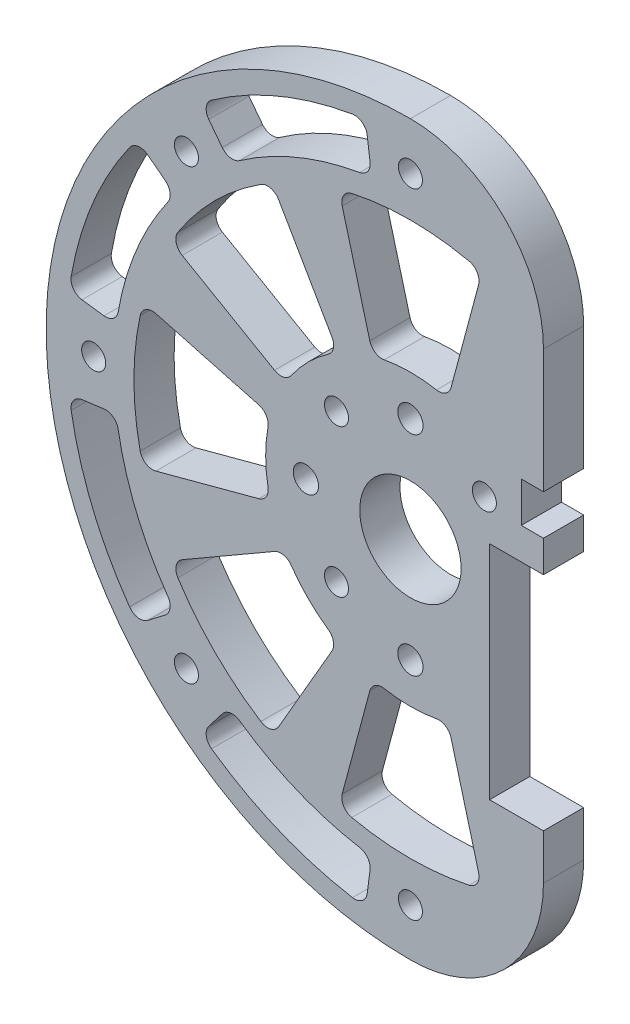
from build123d import *

# Parameters (mm, degrees)
SKETCH1_R                = 57.5
SKETCH1_R_2              = 1.89865
SKETCH1_R_3              = 1.9939
SKETCH1_R_4              = 8
BOSS_EXTRUDE1_DEPTH      = 6.35
CUT_EXTRUDE1_DEPTH       = 82.564836173
SKETCH3_W                = 6.35
SKETCH3_H                = 80
CUT_EXTRUDE3_DEPTH       = 82.564836173
CUT_EXTRUDE5_DEPTH       = 82.564836173
CUT_EXTRUDE7_DEPTH       = 82.564836173
FILLET1_R                = 2
CIRPATTERN1_COUNT        = 8
FILLET1_OF_CIRPATTERN1_R = 2
CUT_EXTRUDE8_DEPTH       = 82.564836173
FILLET2_R                = 2
CIRPATTERN2_COUNT        = 8
FILLET2_OF_CIRPATTERN2_R = 2


with BuildPart() as part:
    # Sketch1 → Boss-Extrude1 (new body)
    with BuildSketch(Plane.XY):
        Circle(SKETCH1_R)
        with Locations((45.315389352, 21.130913087)):
            Circle(SKETCH1_R_2, mode=Mode.SUBTRACT)
        with Locations((49.978847504, 1.454235937)):
            Circle(SKETCH1_R_3, mode=Mode.SUBTRACT)
        Circle(SKETCH1_R_4, mode=Mode.SUBTRACT)
        with Locations((46.467376211, -18.460307366)):
            Circle(SKETCH1_R_3, mode=Mode.SUBTRACT)
        with Locations((0, -16.5)):
            Circle(SKETCH1_R_3, mode=Mode.SUBTRACT)
        with Locations((0, -50)):
            Circle(SKETCH1_R_2, mode=Mode.SUBTRACT)
        with Locations((-16.5, 0)):
            Circle(SKETCH1_R_3, mode=Mode.SUBTRACT)
        with Locations((-11.66726189, -11.66726189)):
            Circle(SKETCH1_R_2, mode=Mode.SUBTRACT)
        with Locations((0, 16.5)):
            Circle(SKETCH1_R_3, mode=Mode.SUBTRACT)
        with Locations((-11.66726189, 11.66726189)):
            Circle(SKETCH1_R_2, mode=Mode.SUBTRACT)
        with Locations((11.66726189, 11.66726189)):
            Circle(SKETCH1_R_2, mode=Mode.SUBTRACT)
        with Locations((-35.355339059, -35.355339059)):
            Circle(SKETCH1_R_2, mode=Mode.SUBTRACT)
        with Locations((-50, 0)):
            Circle(SKETCH1_R_2, mode=Mode.SUBTRACT)
        with Locations((-35.355339059, 35.355339059)):
            Circle(SKETCH1_R_2, mode=Mode.SUBTRACT)
        with Locations((0, 50)):
            Circle(SKETCH1_R_2, mode=Mode.SUBTRACT)
        with Locations((35.355339059, -35.355339059)):
            Circle(SKETCH1_R_2, mode=Mode.SUBTRACT)
    extrude(amount=BOSS_EXTRUDE1_DEPTH)

    # Sketch2 → Cut-Extrude1 (cut, through all)
    with BuildSketch(Plane.XY):
        Polygon((12.5, -29.35), (41, -29.35), (41, 10.65), (44.5, 10.65), (44.5, 17), (41, 17), (41, 32), (21, 32), (21, 17), (17.5, 17), (17.5, 10.65), (21, 10.65), (21, 5.65), (12.5, 5.65), align=None)
    extrude(amount=CUT_EXTRUDE1_DEPTH, mode=Mode.SUBTRACT)

    # Sketch3 → Cut-Extrude3 (cut, through all)
    with BuildSketch(Plane(origin=(0, 0, 0), x_dir=(-1, 0, 0), z_dir=(0, 0, -1))):
        with Locations((-31, 32)):
            Rectangle(SKETCH3_W, SKETCH3_H)
    extrude(amount=-CUT_EXTRUDE3_DEPTH, mode=Mode.SUBTRACT)

    # Sketch4 → Cut-Extrude5 (cut, through all)
    with BuildSketch(Plane.XY):
        with BuildLine():
            Line((21, -36.500002949), (21, -5.372089924))
            Line((21, -5.372089924), (24.175, -5.411516926))
            Line((24.175, -5.411516926), (24.175, -57.5))
            Line((24.175, -57.5), (2.949e-06, -57.5))
            ThreePointArc((2.949e-06, -57.5), (14.849243269, -51.349243269), (21, -36.500002949))
        make_face()
        with BuildLine():
            Line((2.949e-06, 57.5), (24.175, 57.5))
            Line((24.175, 57.5), (24.175, 5.411516926))
            Line((24.175, 5.411516926), (21, 5.372089924))
            Line((21, 5.372089924), (21, 36.500002949))
            ThreePointArc((21, 36.500002949), (14.849243269, 51.349243269), (2.949e-06, 57.5))
        make_face()
    extrude(amount=CUT_EXTRUDE5_DEPTH, mode=Mode.SUBTRACT)


with BuildPart() as cut_extrude5_kept_piece:
    # of the separate pieces the step leaves, the one the design keeps (cut_extrude5_pieces_kept)
    add(part.part.solids().sort_by_distance((2.949e-06, 57.5, 0))[0])

    # Sketch6 → Cut-Extrude7 (cut, through all)
    with BuildSketch(Plane.XY.offset(6.35)):
        with BuildLine():
            Line((-42.162662318, -11.297451319), (-22.071405131, -5.914015181))
            ThreePointArc((-22.071405131, -5.914015181), (-22.85, 0), (-22.071405131, 5.914015181))
            Line((-22.071405131, 5.914015181), (-42.162662318, 11.297451319))
            ThreePointArc((-42.162662318, 11.297451319), (-43.65, 0), (-42.162662318, -11.297451319))
        make_face()
    cut_extrude7 = extrude(amount=-CUT_EXTRUDE7_DEPTH, mode=Mode.SUBTRACT)

    # Fillet1
    fillet1_edges = [cut_extrude5_kept_piece.edges().sort_by_distance(p)[0] for p in [
        (-22.071405131, 5.914015181, 3.175),
        (-22.071405131, -5.914015181, 3.175),
        (-42.162662318, -11.297451319, 3.175),
        (-42.162662318, 11.297451319, 3.175),
    ]]
    fillet(fillet1_edges, radius=FILLET1_R)

    # CirPattern1: Cut-Extrude7 ×8 about axis, 3 skipped
    cirpattern1_axis = Axis((0, 0, 0), (0, 0, -1))
    add([cut_extrude7.rotate(cirpattern1_axis, i * 360 / CIRPATTERN1_COUNT) for i in range(1, CIRPATTERN1_COUNT) if i not in (3, 4, 5)], mode=Mode.SUBTRACT)

    # Fillet1 of CirPattern1
    fillet1_of_cirpattern1_edges = [cut_extrude5_kept_piece.edges().sort_by_distance(p)[0] for p in [
        (-11.425, 19.788680476, 3.175),
        (-19.788680476, 11.425, 3.175),
        (-37.802008875, 21.825, 3.175),
        (-21.825, 37.802008875, 3.175),
        (5.914015181, 22.071405131, 3.175),
        (-5.914015181, 22.071405131, 3.175),
        (-11.297451319, 42.162662318, 3.175),
        (11.297451319, 42.162662318, 3.175),
        (-5.914015181, -22.071405131, 3.175),
        (5.914015181, -22.071405131, 3.175),
        (11.297451319, -42.162662318, 3.175),
        (-11.297451319, -42.162662318, 3.175),
        (-19.788680476, -11.425, 3.175),
        (-11.425, -19.788680476, 3.175),
        (-21.825, -37.802008875, 3.175),
        (-37.802008875, -21.825, 3.175),
    ]]
    fillet(fillet1_of_cirpattern1_edges, radius=FILLET1_OF_CIRPATTERN1_R)

    # Sketch7 → Cut-Extrude8 (cut, through all)
    with BuildSketch(Plane.XY.offset(6.35)):
        with BuildLine():
            Line((-43.098920211, 33.070964631), (-37.148770159, 28.505253913))
            ThreePointArc((-37.148770159, 28.505253913), (-43.26065911, 17.91915172), (-46.424405634, 6.111888951))
            Line((-46.424405634, 6.111888951), (-53.860242094, 7.090835392))
            ThreePointArc((-53.860242094, 7.090835392), (-50.189755604, 20.789277463), (-43.098920211, 33.070964631))
        make_face()
    cut_extrude8 = extrude(amount=-CUT_EXTRUDE8_DEPTH, mode=Mode.SUBTRACT)

    # Fillet2
    fillet2_edges = [cut_extrude5_kept_piece.edges().sort_by_distance(p)[0] for p in [
        (-53.860242094, 7.090835392, 3.175),
        (-43.098920211, 33.070964631, 3.175),
        (-37.148770159, 28.505253913, 3.175),
        (-46.424405634, 6.111888951, 3.175),
    ]]
    fillet(fillet2_edges, radius=FILLET2_R)

    # CirPattern2: Cut-Extrude8 ×8 about axis, 4 skipped
    cirpattern2_axis = Axis((0, 0, 0), (0, 0, -1))
    add([cut_extrude8.rotate(cirpattern2_axis, i * 360 / CIRPATTERN2_COUNT) for i in range(1, CIRPATTERN2_COUNT) if i not in (2, 3, 4, 5)], mode=Mode.SUBTRACT)

    # Fillet2 of CirPattern2
    fillet2_of_cirpattern2_edges = [cut_extrude5_kept_piece.edges().sort_by_distance(p)[0] for p in [
        (-33.070964631, 43.098920211, 3.175),
        (-7.090835392, 53.860242094, 3.175),
        (-6.111888951, 46.424405634, 3.175),
        (-28.505253913, 37.148770159, 3.175),
        (-7.090835392, -53.860242094, 3.175),
        (-33.070964631, -43.098920211, 3.175),
        (-28.505253913, -37.148770159, 3.175),
        (-6.111888951, -46.424405634, 3.175),
        (-43.098920211, -33.070964631, 3.175),
        (-53.860242094, -7.090835392, 3.175),
        (-46.424405634, -6.111888951, 3.175),
        (-37.148770159, -28.505253913, 3.175),
    ]]
    fillet(fillet2_of_cirpattern2_edges, radius=FILLET2_OF_CIRPATTERN2_R)


solid = cut_extrude5_kept_piece.part
